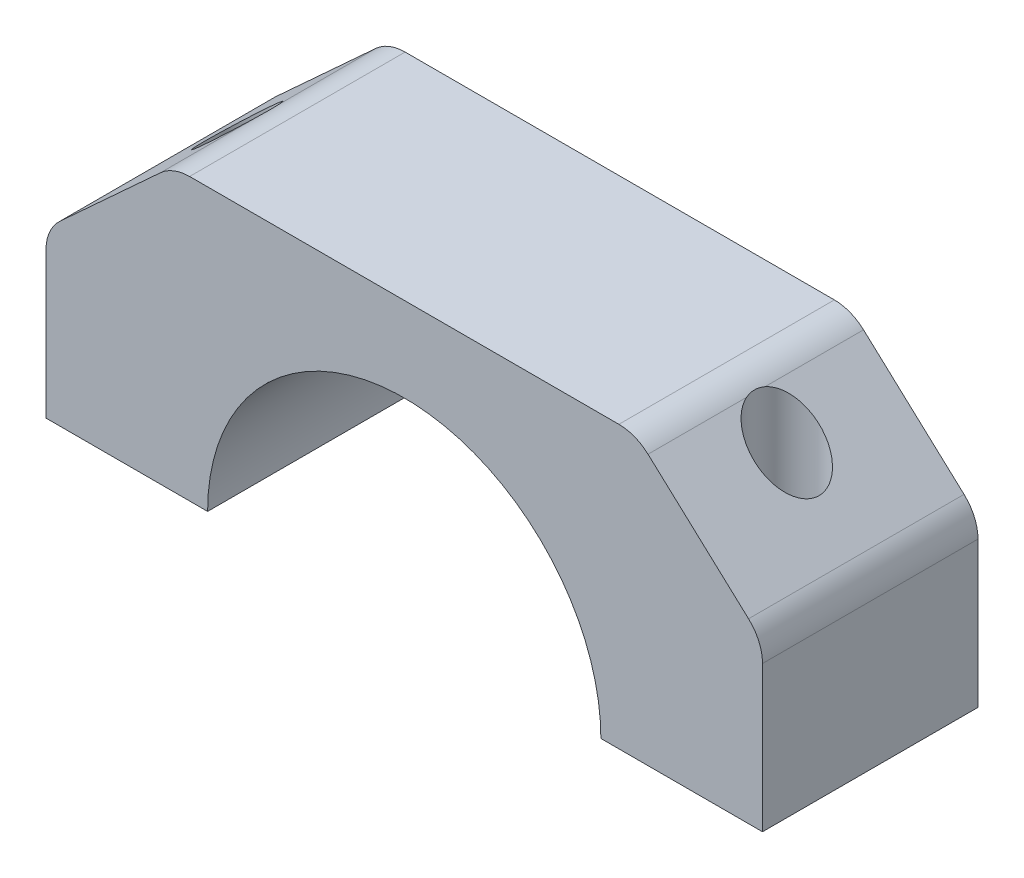
from build123d import *

# Parameters (mm, degrees)
EXTRUDE_1_DEPTH     = 20
SKETCH_2_R          = 3
CUT_EXTRUDE_1_DEPTH = 20
SKETCH_3_R          = 1.75
CUT_EXTRUDE_2_DEPTH = 27.088377855


with BuildPart() as part:
    # 草图1 → 凸台-拉伸1 (new body)
    with BuildSketch(Plane.XY):
        with BuildLine():
            Line((-33.25, 0), (-18.25, 0))
            ThreePointArc((-18.25, 0), (0, 18.25), (18.25, 0))
            Line((18.25, 0), (33.25, 0))
            Line((33.25, 0), (33.25, 13.52748426))
            ThreePointArc((33.25, 13.52748426), (32.911797538, 15.137216782), (31.954380604, 16.474741552))
            Line((31.954380604, 16.474741552), (22.624644973, 25.035635147))
            ThreePointArc((22.624644973, 25.035635147), (21.371293457, 25.815912507), (19.920264369, 26.088377855))
            Line((19.920264369, 26.088377855), (-19.920264369, 26.088377855))
            ThreePointArc((-19.920264369, 26.088377855), (-21.371293457, 25.815912507), (-22.624644973, 25.035635147))
            Line((-22.624644973, 25.035635147), (-31.954380604, 16.474741552))
            ThreePointArc((-31.954380604, 16.474741552), (-32.911797538, 15.137216782), (-33.25, 13.52748426))
            Line((-33.25, 13.52748426), (-33.25, 0))
        make_face()
    extrude(amount=EXTRUDE_1_DEPTH)

    # 草图2 → 切除-拉伸1 (cut)
    with BuildSketch(Plane(origin=(0, 26.088377855, 0), x_dir=(1, 0, 0), z_dir=(0, 1, 0))):
        with Locations((-25.5, -10)):
            Circle(SKETCH_2_R)
        with Locations((25.5, -10)):
            Circle(SKETCH_2_R)
    extrude(amount=-CUT_EXTRUDE_1_DEPTH, mode=Mode.SUBTRACT)

    # 草图3 → 切除-拉伸2 (cut, through all)
    with BuildSketch(Plane(origin=(0, 26.088377855, 0), x_dir=(1, 0, 0), z_dir=(0, 1, 0))):
        with Locations((25.5, -10)):
            Circle(SKETCH_3_R)
        with Locations((-25.5, -10)):
            Circle(SKETCH_3_R)
    extrude(amount=-CUT_EXTRUDE_2_DEPTH, mode=Mode.SUBTRACT)


solid = part.part
